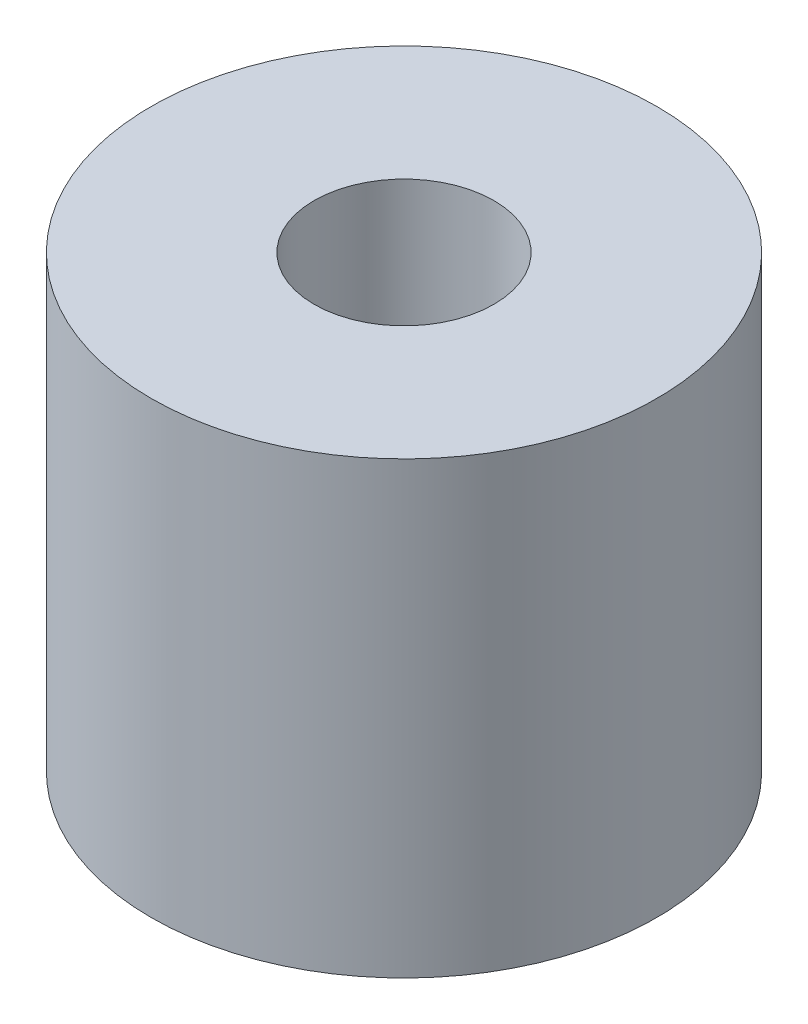
from build123d import *

# Parameters (mm, degrees)
CROQUIS1_R              = 4.5
CROQUIS1_R_2            = 1.6
SALIENTE_EXTRUIR1_DEPTH = 8


with BuildPart() as part:
    # Croquis1 → Saliente-Extruir1 (new body)
    with BuildSketch(Plane(origin=(0, 0, 0), x_dir=(1, 0, 0), z_dir=(0, 1, 0))):
        Circle(CROQUIS1_R)
        Circle(CROQUIS1_R_2, mode=Mode.SUBTRACT)
    extrude(amount=SALIENTE_EXTRUIR1_DEPTH)


solid = part.part
